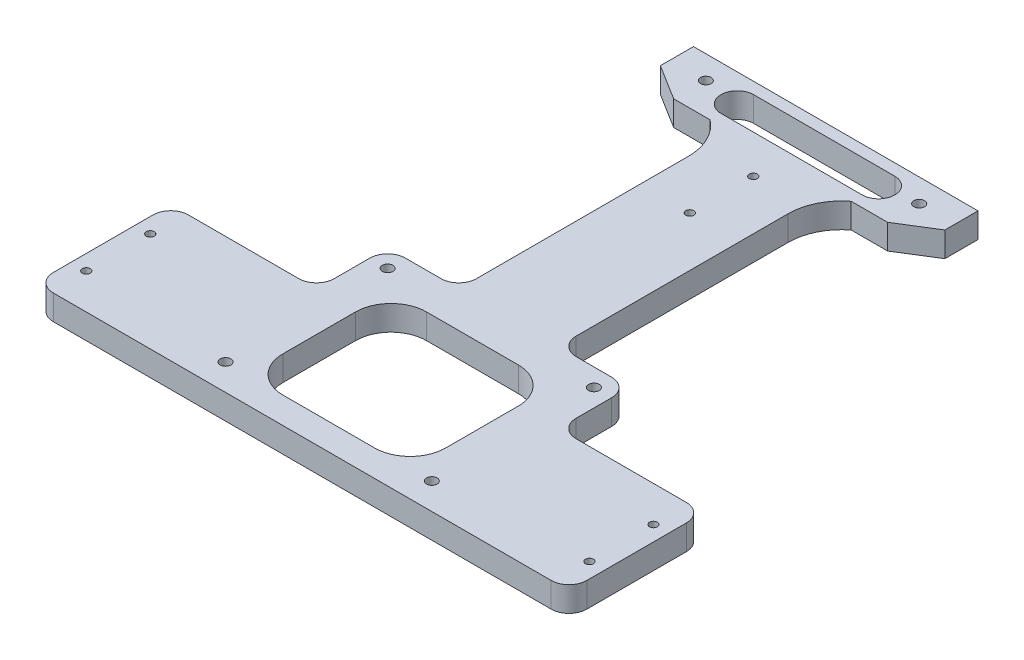
from build123d import *

# Parameters (mm, degrees)
BOSS_EXTRUDE3_DEPTH     = 7
CUT_EXTRUDE1_DEPTH      = 10
SKETCH3_R               = 1.125
CUT_EXTRUDE3_DEPTH      = 1
CUT_EXTRUDE3_DEPTH_BACK = 8
SKETCH4_R               = 1.5
BOSS_EXTRUDE4_DEPTH     = 7
SKETCH5_R               = 1.5
CUT_EXTRUDE4_DEPTH      = 1
CUT_EXTRUDE4_DEPTH_BACK = 8
SKETCH6_R               = 1.125
CUT_EXTRUDE5_DEPTH      = 1
CUT_EXTRUDE5_DEPTH_BACK = 8
CUT_EXTRUDE6_DEPTH      = 1
CUT_EXTRUDE6_DEPTH_BACK = 8


with BuildPart() as part:
    # Sketch1 → Boss-Extrude3 (new body)
    with BuildSketch(Plane(origin=(0, 0, 0), x_dir=(1, 0, 0), z_dir=(0, 1, 0))):
        with BuildLine():
            Line((283.825365173, -12.637997433), (247.825365173, -12.637997433))
            Line((247.825365173, -12.637997433), (247.825365173, -17.637997433))
            ThreePointArc((247.825365173, -17.637997433), (246.360899079, -21.173531339), (242.825365173, -22.637997433))
            Line((242.825365173, -22.637997433), (184.825365173, -22.637997433))
            ThreePointArc((184.825365173, -22.637997433), (181.289831267, -21.173531339), (179.825365173, -17.637997433))
            Line((179.825365173, -17.637997433), (179.825365173, -12.637997433))
            Line((179.825365173, -12.637997433), (143.825365173, -12.637997433))
            ThreePointArc((143.825365173, -12.637997433), (140.289831267, -11.173531339), (138.825365173, -7.637997433))
            Line((138.825365173, -7.637997433), (138.825365173, 20.362002567))
            ThreePointArc((138.825365173, 20.362002567), (140.289831267, 23.897536473), (143.825365173, 25.362002567))
            Line((143.825365173, 25.362002567), (174.825365173, 25.362002567))
            ThreePointArc((174.825365173, 25.362002567), (178.360899079, 26.826468661), (179.825365173, 30.362002567))
            Line((179.825365173, 30.362002567), (179.825365173, 40.362002567))
            ThreePointArc((179.825365173, 40.362002567), (181.289831267, 43.897536473), (184.825365173, 45.362002567))
            Line((184.825365173, 45.362002567), (194.825365173, 45.362002567))
            ThreePointArc((194.825365173, 45.362002567), (198.360899079, 46.826468661), (199.825365173, 50.362002567))
            Line((199.825365173, 50.362002567), (199.825365173, 117.362002567))
            ThreePointArc((199.825365173, 117.362002567), (198.360899079, 120.897536473), (194.825365173, 122.362002567))
            Line((194.825365173, 122.362002567), (184.825365173, 122.362002567))
            ThreePointArc((184.825365173, 122.362002567), (181.289831267, 123.826468661), (179.825365173, 127.362002567))
            Line((179.825365173, 127.362002567), (179.825365173, 132.362002567))
            ThreePointArc((179.825365173, 132.362002567), (181.289831267, 135.897536473), (184.825365173, 137.362002567))
            Line((184.825365173, 137.362002567), (242.825365173, 137.362002567))
            ThreePointArc((242.825365173, 137.362002567), (246.360899079, 135.897536473), (247.825365173, 132.362002567))
            Line((247.825365173, 132.362002567), (247.825365173, 127.362002567))
            ThreePointArc((247.825365173, 127.362002567), (246.360899079, 123.826468661), (242.825365173, 122.362002567))
            Line((242.825365173, 122.362002567), (232.825365173, 122.362002567))
            ThreePointArc((232.825365173, 122.362002567), (229.289831267, 120.897536473), (227.825365173, 117.362002567))
            Line((227.825365173, 117.362002567), (227.825365173, 50.362002567))
            ThreePointArc((227.825365173, 50.362002567), (229.289831267, 46.826468661), (232.825365173, 45.362002567))
            Line((232.825365173, 45.362002567), (242.825365173, 45.362002567))
            ThreePointArc((242.825365173, 45.362002567), (246.360899079, 43.897536473), (247.825365173, 40.362002567))
            Line((247.825365173, 40.362002567), (247.825365173, 30.362002567))
            ThreePointArc((247.825365173, 30.362002567), (249.289831267, 26.826468661), (252.825365173, 25.362002567))
            Line((252.825365173, 25.362002567), (283.825365173, 25.362002567))
            ThreePointArc((283.825365173, 25.362002567), (287.360899079, 23.897536473), (288.825365173, 20.362002567))
            Line((288.825365173, 20.362002567), (288.825365173, -7.637997433))
            ThreePointArc((288.825365173, -7.637997433), (287.360899079, -11.173531339), (283.825365173, -12.637997433))
        make_face()
    extrude(amount=BOSS_EXTRUDE3_DEPTH)

    # Sketch2 → Cut-Extrude1 (cut)
    with BuildSketch(Plane(origin=(0, 7, 0), x_dir=(1, 0, 0), z_dir=(0, 1, 0))):
        with BuildLine():
            Line((179.825365173, -12.637997433), (247.825365173, -12.637997433))
            Line((247.825365173, -12.637997433), (247.825365173, -17.637997433))
            ThreePointArc((247.825365173, -17.637997433), (246.360899079, -21.173531339), (242.825365173, -22.637997433))
            Line((242.825365173, -22.637997433), (184.825365173, -22.637997433))
            ThreePointArc((184.825365173, -22.637997433), (181.289831267, -21.173531339), (179.825365173, -17.637997433))
            Line((179.825365173, -17.637997433), (179.825365173, -12.637997433))
        make_face()
    extrude(amount=-CUT_EXTRUDE1_DEPTH, mode=Mode.SUBTRACT)

    # Sketch3 → Cut-Extrude3 (cut, two sides)
    with BuildSketch(Plane(origin=(0, 7, 0), x_dir=(1, 0, 0), z_dir=(0, 1, 0))) as cut_extrude3_sk:
        with Locations((143.075365173, 15.362002567)):
            Circle(SKETCH3_R)
        with Locations((143.075365173, -2.637997433)):
            Circle(SKETCH3_R)
        with Locations((284.575365173, -2.637997433)):
            Circle(SKETCH3_R)
        with Locations((284.575365173, 15.362002567)):
            Circle(SKETCH3_R)
        with BuildLine():
            Line((236.729776069, 25.219549299), (236.729776069, 4.789235296))
            ThreePointArc((236.729776069, 4.789235296), (233.800843881, -2.281832516), (226.729776069, -5.210764704))
            Line((226.729776069, -5.210764704), (200.920954278, -5.210764704))
            ThreePointArc((200.920954278, -5.210764704), (193.849886466, -2.281832516), (190.920954278, 4.789235296))
            Line((190.920954278, 4.789235296), (190.920954278, 25.219549299))
            ThreePointArc((190.920954278, 25.219549299), (193.849886466, 32.290617111), (200.920954278, 35.219549299))
            Line((200.920954278, 35.219549299), (226.729776069, 35.219549299))
            ThreePointArc((226.729776069, 35.219549299), (233.800843881, 32.290617111), (236.729776069, 25.219549299))
        make_face()
    extrude(amount=CUT_EXTRUDE3_DEPTH, mode=Mode.SUBTRACT)
    extrude(cut_extrude3_sk.sketch, amount=-CUT_EXTRUDE3_DEPTH_BACK, mode=Mode.SUBTRACT)

    # Sketch4 → Boss-Extrude4 (add)
    with BuildSketch(Plane(origin=(0, 7, 0), x_dir=(1, 0, 0), z_dir=(0, 1, 0))):
        with BuildLine():
            Line((233.679703761, 121.865339942), (243.89819588, 121.865339942))
            Line((243.89819588, 121.865339942), (253.825365173, 128.052186148))
            Line((253.825365173, 128.052186148), (253.825365173, 137.362002567))
            Line((253.825365173, 137.362002567), (173.825365173, 137.362002567))
            Line((173.825365173, 137.362002567), (173.825365173, 128.052186148))
            Line((173.825365173, 128.052186148), (183.752534467, 121.865339942))
            Line((183.752534467, 121.865339942), (193.971026586, 121.865339942))
            ThreePointArc((193.971026586, 121.865339942), (198.282425053, 116.602256541), (199.825365173, 109.975980106))
            Line((199.825365173, 109.975980106), (199.825365173, 83.862002567))
            Line((199.825365173, 83.862002567), (227.825365173, 83.862002567))
            Line((227.825365173, 83.862002567), (227.825365173, 109.975980106))
            ThreePointArc((227.825365173, 109.975980106), (229.368305294, 116.602256541), (233.679703761, 121.865339942))
        make_face()
        with Locations((183.89819588, 129.862002567)):
            Circle(SKETCH4_R, mode=Mode.SUBTRACT)
        with Locations((243.89819588, 129.862002567)):
            Circle(SKETCH4_R, mode=Mode.SUBTRACT)
    extrude(amount=-BOSS_EXTRUDE4_DEPTH)

    # Sketch5 → Cut-Extrude4 (cut, two sides)
    with BuildSketch(Plane(origin=(0, 7, 0), x_dir=(1, 0, 0), z_dir=(0, 1, 0))) as cut_extrude4_sk:
        with Locations((183.825365173, 130.832171384)):
            Circle(SKETCH5_R)
        with Locations((243.825365173, 130.832171384)):
            Circle(SKETCH5_R)
        with Locations((242.825365173, 40.362002567)):
            Circle(SKETCH5_R)
        with Locations((184.825365173, 40.362002567)):
            Circle(SKETCH5_R)
        with Locations((184.825365173, -5.210764704)):
            Circle(SKETCH5_R)
        with Locations((242.825365173, -5.210764704)):
            Circle(SKETCH5_R)
    extrude(amount=CUT_EXTRUDE4_DEPTH, mode=Mode.SUBTRACT)
    extrude(cut_extrude4_sk.sketch, amount=-CUT_EXTRUDE4_DEPTH_BACK, mode=Mode.SUBTRACT)

    # Sketch6 → Cut-Extrude5 (cut, two sides)
    with BuildSketch(Plane(origin=(0, 7, 0), x_dir=(1, 0, 0), z_dir=(0, 1, 0))) as cut_extrude5_sk:
        with Locations((284.575365173, 15.362002567)):
            Circle(SKETCH6_R)
        with Locations((213.825365173, 96.329183022)):
            Circle(SKETCH6_R)
        with Locations((213.825365173, 114.177699089)):
            Circle(SKETCH6_R)
    extrude(amount=CUT_EXTRUDE5_DEPTH, mode=Mode.SUBTRACT)
    extrude(cut_extrude5_sk.sketch, amount=-CUT_EXTRUDE5_DEPTH_BACK, mode=Mode.SUBTRACT)

    # Sketch7 → Cut-Extrude6 (cut, two sides)
    with BuildSketch(Plane(origin=(0, 7, 0), x_dir=(1, 0, 0), z_dir=(0, 1, 0))) as cut_extrude6_sk:
        with BuildLine():
            Line((193.971026586, 134.106855399), (233.679703761, 134.106855399))
            ThreePointArc((233.679703761, 134.106855399), (238.2529795, 129.533579659), (233.679703761, 124.96030392))
            Line((233.679703761, 124.96030392), (193.971026586, 124.96030392))
            ThreePointArc((193.971026586, 124.96030392), (189.397750847, 129.533579659), (193.971026586, 134.106855399))
        make_face()
    extrude(amount=CUT_EXTRUDE6_DEPTH, mode=Mode.SUBTRACT)
    extrude(cut_extrude6_sk.sketch, amount=-CUT_EXTRUDE6_DEPTH_BACK, mode=Mode.SUBTRACT)


solid = part.part
